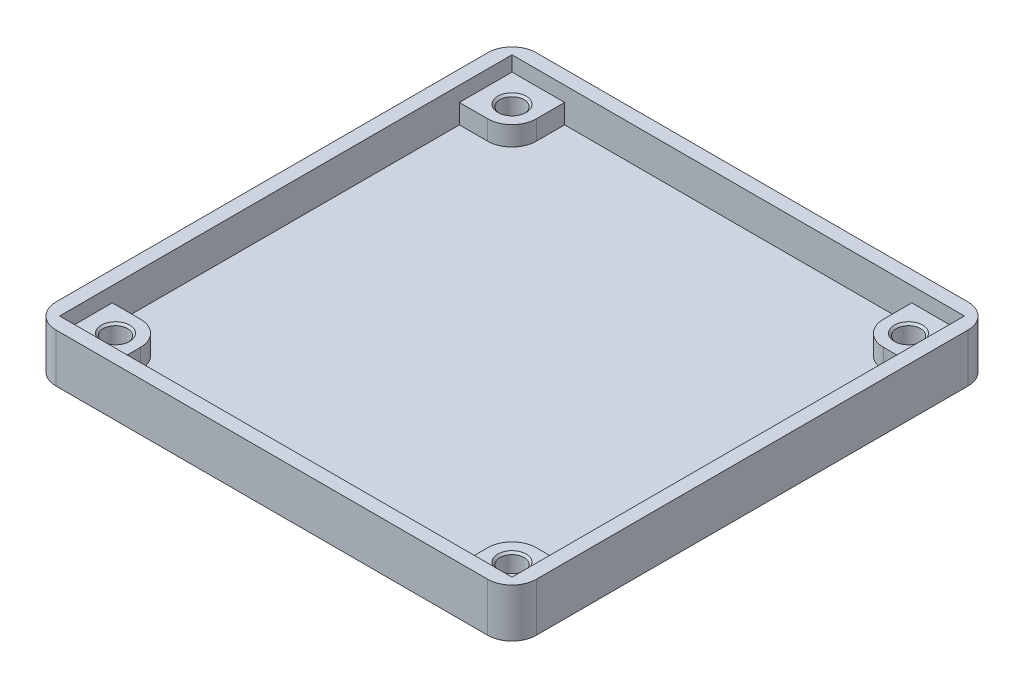
from build123d import *

# Parameters (mm, degrees)
SKETCH1_W           = 59.35
SKETCH1_H           = 59.35
BOSS_EXTRUDE1_DEPTH = 6
SKETCH2_R           = 1.5
CUT_EXTRUDE1_DEPTH  = 7
SKETCH7_W           = 55.9
SKETCH7_H           = 55.9
CUT_EXTRUDE3_DEPTH  = 1.85
CUT_EXTRUDE4_DEPTH  = 2.4
FILLET1_R           = 3
CHAMFER1_SIZE       = 0.25


with BuildPart() as part:
    # Sketch1 → Boss-Extrude1 (new body)
    with BuildSketch(Plane(origin=(0, 0, 0), x_dir=(1, 0, 0), z_dir=(0, 1, 0))):
        Rectangle(SKETCH1_W, SKETCH1_H)
    extrude(amount=BOSS_EXTRUDE1_DEPTH)

    # Sketch2 → Cut-Extrude1 (cut, through all)
    with BuildSketch(Plane(origin=(0, 6, 0), x_dir=(1, 0, 0), z_dir=(0, 1, 0))):
        with Locations((-24.5, 24.5)):
            Circle(SKETCH2_R)
        with Locations((24.5, 24.5)):
            Circle(SKETCH2_R)
        with Locations((-24.5, -24.5)):
            Circle(SKETCH2_R)
        with Locations((24.5, -24.5)):
            Circle(SKETCH2_R)
    extrude(amount=-CUT_EXTRUDE1_DEPTH, mode=Mode.SUBTRACT)

    # Sketch7 → Cut-Extrude3 (cut)
    with BuildSketch(Plane(origin=(0, 6, 0), x_dir=(1, 0, 0), z_dir=(0, 1, 0))):
        Rectangle(SKETCH7_W, SKETCH7_H)
    extrude(amount=-CUT_EXTRUDE3_DEPTH, mode=Mode.SUBTRACT)

    # Sketch8 → Cut-Extrude4 (cut)
    with BuildSketch(Plane(origin=(0, 4.15, 0), x_dir=(1, 0, 0), z_dir=(0, 1, 0))):
        Polygon((-27.95, 21.45), (-21.45, 21.45), (-21.45, 27.95), (21.45, 27.95), (21.45, 21.45), (27.95, 21.45), (27.95, -21.45), (21.45, -21.45), (21.45, -27.95), (-21.45, -27.95), (-21.45, -21.45), (-27.95, -21.45), align=None)
    extrude(amount=-CUT_EXTRUDE4_DEPTH, mode=Mode.SUBTRACT)

    # Fillet1
    fillet1_edges = [part.edges().sort_by_distance(p)[0] for p in [
        (-21.45, 2.95, -21.45),
        (21.45, 2.95, -21.45),
        (21.45, 2.95, 21.45),
        (-21.45, 2.95, 21.45),
        (-29.675, 3, 29.675),
        (-29.675, 3, -29.675),
        (29.675, 3, -29.675),
        (29.675, 3, 29.675),
    ]]
    fillet(fillet1_edges, radius=FILLET1_R)

    # Chamfer1
    chamfer1_edges = [part.edges().sort_by_distance(p)[0] for p in [
        (-26, 4.15, -24.5),
        (23, 4.15, 24.5),
        (-26, 4.15, 24.5),
        (23, 4.15, -24.5),
    ]]
    chamfer(chamfer1_edges, length=CHAMFER1_SIZE)


solid = part.part
